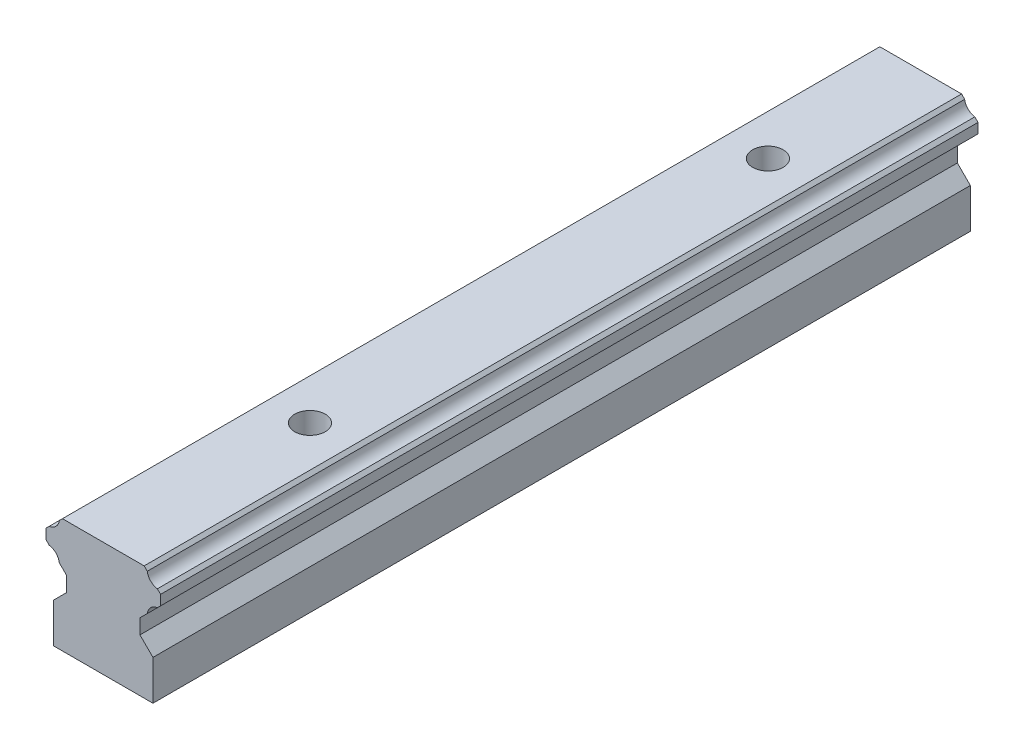
from build123d import *

# Parameters (mm, degrees)
BOSS_EXTRUDE1_DEPTH = 107.00004
SKETCH2_R           = 2
CUT_EXTRUDE1_DEPTH  = 16


with BuildPart() as part:
    # Sketch1 → Boss-Extrude1 (new body)
    with BuildSketch(Plane.XY):
        with BuildLine():
            Line((-6.5, 0), (6.5, 0))
            Line((6.5, 0), (6.5, 5.2))
            Line((6.5, 5.2), (4.8, 6.9))
            Line((4.8, 6.9), (4.8, 8.84))
            Line((4.8, 8.84), (5.754868434, 9.794868434))
            ThreePointArc((5.754868434, 9.794868434), (6.196913421, 10.683086579), (7.085131566, 11.125131566))
            Line((7.085131566, 11.125131566), (7.5, 11.54))
            Line((7.5, 11.54), (7.5, 12.85))
            Line((7.5, 12.85), (7.08164233, 13.26835767))
            ThreePointArc((7.08164233, 13.26835767), (6.196913421, 13.709913421), (5.75535767, 14.59464233))
            Line((5.75535767, 14.59464233), (5.35, 15))
            Line((5.35, 15), (-5.35, 15))
            Line((-5.35, 15), (-5.75535767, 14.59464233))
            ThreePointArc((-5.75535767, 14.59464233), (-6.196913421, 13.709913421), (-7.08164233, 13.26835767))
            Line((-7.08164233, 13.26835767), (-7.5, 12.85))
            Line((-7.5, 12.85), (-7.5, 11.54))
            Line((-7.5, 11.54), (-7.085131566, 11.125131566))
            ThreePointArc((-7.085131566, 11.125131566), (-6.196913421, 10.683086579), (-5.754868434, 9.794868434))
            Line((-5.754868434, 9.794868434), (-4.8, 8.84))
            Line((-4.8, 8.84), (-4.8, 6.9))
            Line((-4.8, 6.9), (-6.5, 5.2))
            Line((-6.5, 5.2), (-6.5, 0))
        make_face()
    extrude(amount=BOSS_EXTRUDE1_DEPTH)

    # Sketch2 → Cut-Extrude1 (cut, through all)
    with BuildSketch(Plane(origin=(0, 15, 0), x_dir=(1, 0, 0), z_dir=(0, 1, 0))):
        with Locations((0, -20)):
            Circle(SKETCH2_R)
        with Locations((0, -79.944)):
            Circle(SKETCH2_R)
    extrude(amount=-CUT_EXTRUDE1_DEPTH, mode=Mode.SUBTRACT)


solid = part.part
